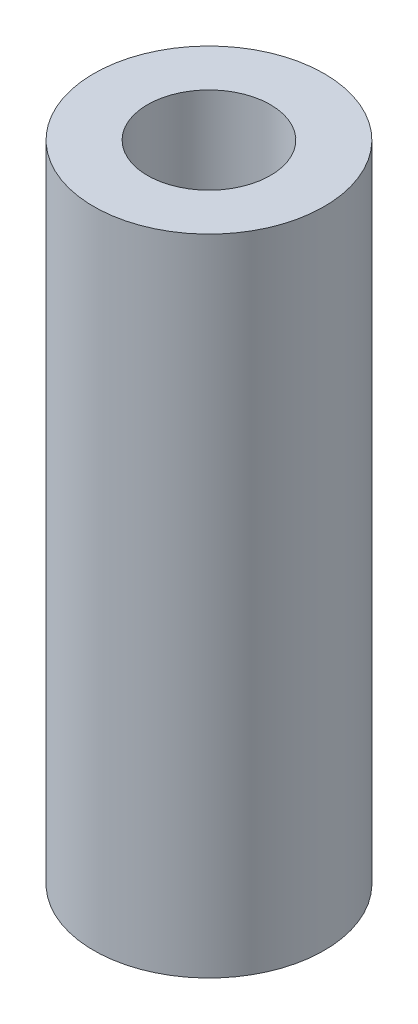
from build123d import *


with BuildPart() as part:
    # Эскиз1 → Повернуть1 (revolve)
    with BuildSketch(Plane.XY):
        Polygon((0, 0), (-7.5, 0), (-7.5, 41.936780211), (-4, 41.936780211), (-4, 18), (0, 18), align=None)
    revolve(axis=Axis((0, -2.345001298, 0), (0, 1, 0)))


solid = part.part
